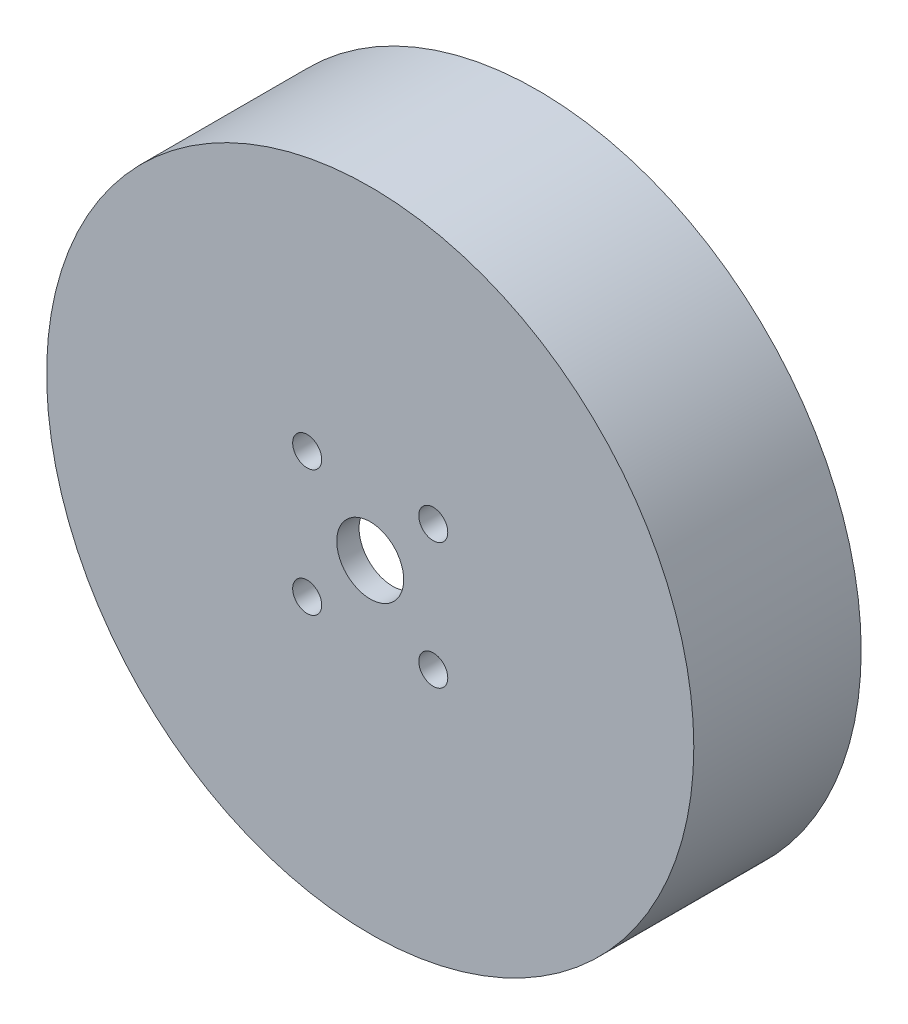
from build123d import *

# Parameters (mm, degrees)
SKETCH_1_R          = 29
EXTRUDE_1_DEPTH     = 15
SKETCH_2_R          = 25
CUT_EXTRUDE_1_DEPTH = 13
CUT_EXTRUDE_2_REACH = 17
SKETCH_3_R          = 1.3
SKETCH_3_R_2        = 3
EXTRUDE_3_DEPTH     = 10


with BuildPart() as part:
    # 草图1 → 凸台-拉伸1 (new body)
    with BuildSketch(Plane.XY):
        Circle(SKETCH_1_R)
    extrude(amount=EXTRUDE_1_DEPTH)

    # 草图2 → 切除-拉伸1 (cut)
    with BuildSketch(Plane(origin=(0, 0, 0), x_dir=(-1, 0, 0), z_dir=(0, 0, -1))):
        Circle(SKETCH_2_R)
    extrude(amount=-CUT_EXTRUDE_1_DEPTH, mode=Mode.SUBTRACT)

    # 草图3 → 切除-拉伸2 (cut, up to next)
    with BuildSketch(Plane.XY.offset(15), mode=Mode.PRIVATE) as cut_extrude_2_sk1:
        with Locations((5.65, 5.65)):
            Circle(SKETCH_3_R)
    cut_extrude_2_tool1 = extrude(cut_extrude_2_sk1.sketch, amount=-CUT_EXTRUDE_2_REACH, mode=Mode.PRIVATE) & part.part
    add(cut_extrude_2_tool1.solids().sort_by_distance((5.65, 5.65, 15))[0], mode=Mode.SUBTRACT)
    # 草图3 → 切除-拉伸2 (cut, up to next)
    with BuildSketch(Plane.XY.offset(15), mode=Mode.PRIVATE) as cut_extrude_2_sk2:
        with Locations((5.65, -5.65)):
            Circle(SKETCH_3_R)
    cut_extrude_2_tool2 = extrude(cut_extrude_2_sk2.sketch, amount=-CUT_EXTRUDE_2_REACH, mode=Mode.PRIVATE) & part.part
    add(cut_extrude_2_tool2.solids().sort_by_distance((5.65, -5.65, 15))[0], mode=Mode.SUBTRACT)
    # 草图3 → 切除-拉伸2 (cut, up to next)
    with BuildSketch(Plane.XY.offset(15), mode=Mode.PRIVATE) as cut_extrude_2_sk3:
        with Locations((-5.65, -5.65)):
            Circle(SKETCH_3_R)
    cut_extrude_2_tool3 = extrude(cut_extrude_2_sk3.sketch, amount=-CUT_EXTRUDE_2_REACH, mode=Mode.PRIVATE) & part.part
    add(cut_extrude_2_tool3.solids().sort_by_distance((-5.65, -5.65, 15))[0], mode=Mode.SUBTRACT)
    # 草图3 → 切除-拉伸2 (cut, up to next)
    with BuildSketch(Plane.XY.offset(15), mode=Mode.PRIVATE) as cut_extrude_2_sk4:
        with Locations((-5.65, 5.65)):
            Circle(SKETCH_3_R)
    cut_extrude_2_tool4 = extrude(cut_extrude_2_sk4.sketch, amount=-CUT_EXTRUDE_2_REACH, mode=Mode.PRIVATE) & part.part
    add(cut_extrude_2_tool4.solids().sort_by_distance((-5.65, 5.65, 15))[0], mode=Mode.SUBTRACT)
    # 草图3 → 切除-拉伸2 (cut, up to next)
    with BuildSketch(Plane.XY.offset(15), mode=Mode.PRIVATE) as cut_extrude_2_sk5:
        Circle(SKETCH_3_R_2)
    cut_extrude_2_tool5 = extrude(cut_extrude_2_sk5.sketch, amount=-CUT_EXTRUDE_2_REACH, mode=Mode.PRIVATE) & part.part
    add(cut_extrude_2_tool5.solids().sort_by_distance((0, 0, 15))[0], mode=Mode.SUBTRACT)

    # 草图4 → 凸台-拉伸3 (add)
    with BuildSketch(Plane(origin=(0, 0, 13), x_dir=(-1, 0, 0), z_dir=(0, 0, -1))):
        with BuildLine():
            Line((3.475322722, 16.89629048), (5.036699597, 24.487377507))
            ThreePointArc((5.036699597, 24.487377507), (-0.382728828, 24.997070201), (-5.784012851, 24.321702147))
            Line((-5.784012851, 24.321702147), (-3.990968867, 16.781974482))
            ThreePointArc((-3.990968867, 16.781974482), (-0.264082892, 17.247978439), (3.475322722, 16.89629048))
        make_face()
        with BuildLine():
            Line((16.370278146, 5.438427476), (23.725040792, 7.881778951))
            ThreePointArc((23.725040792, 7.881778951), (21.4567334, 12.829987989), (18.171205497, 17.169953138))
            Line((18.171205497, 17.169953138), (12.538131793, 11.847267665))
            ThreePointArc((12.538131793, 11.847267665), (14.805146046, 8.852691712), (16.370278146, 5.438427476))
        make_face()
        with BuildLine():
            Line((12.894955424, -11.457863003), (18.688341195, -16.605598556))
            ThreePointArc((18.688341195, -16.605598556), (21.839462229, -12.167082212), (23.955218348, -7.151749009))
            Line((23.955218348, -7.151749009), (16.52910066, -4.934706816))
            ThreePointArc((16.52910066, -4.934706816), (15.069228938, -8.395286727), (12.894955424, -11.457863003))
        make_face()
        with BuildLine():
            Line((-3.475322722, -16.89629048), (-5.036699597, -24.487377507))
            ThreePointArc((-5.036699597, -24.487377507), (0.382728828, -24.997070201), (5.784012851, -24.321702147))
            Line((5.784012851, -24.321702147), (3.990968867, -16.781974482))
            ThreePointArc((3.990968867, -16.781974482), (0.264082892, -17.247978439), (-3.475322722, -16.89629048))
        make_face()
        with BuildLine():
            Line((-16.370278146, -5.438427476), (-23.725040792, -7.881778951))
            ThreePointArc((-23.725040792, -7.881778951), (-21.4567334, -12.829987989), (-18.171205497, -17.169953138))
            Line((-18.171205497, -17.169953138), (-12.538131793, -11.847267665))
            ThreePointArc((-12.538131793, -11.847267665), (-14.805146046, -8.852691712), (-16.370278146, -5.438427476))
        make_face()
        with BuildLine():
            Line((-12.894955424, 11.457863003), (-18.688341195, 16.605598556))
            ThreePointArc((-18.688341195, 16.605598556), (-21.839462229, 12.167082212), (-23.955218348, 7.151749009))
            Line((-23.955218348, 7.151749009), (-16.52910066, 4.934706816))
            ThreePointArc((-16.52910066, 4.934706816), (-15.069228938, 8.395286727), (-12.894955424, 11.457863003))
        make_face()
    extrude(amount=EXTRUDE_3_DEPTH)


solid = part.part
